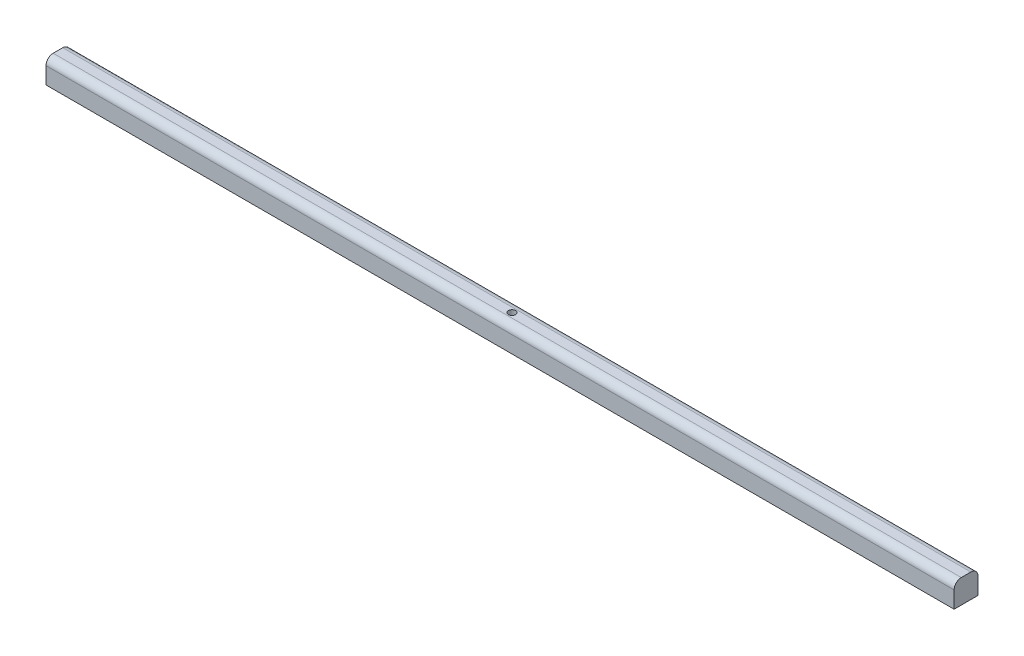
from build123d import *

# Parameters (mm, degrees)
SKETCH1_W           = 380
SKETCH1_H           = 10
BOSS_EXTRUDE1_DEPTH = 10
FILLET1_R           = 3
SKETCH2_R           = 1.5
CUT_EXTRUDE1_DEPTH  = 10


with BuildPart() as part:
    # Sketch1 → Boss-Extrude1 (new body)
    with BuildSketch(Plane(origin=(0, 0, 0), x_dir=(1, 0, 0), z_dir=(0, 1, 0))):
        Rectangle(SKETCH1_W, SKETCH1_H)
    extrude(amount=BOSS_EXTRUDE1_DEPTH)

    # Fillet1
    fillet1_edges = [part.edges().sort_by_distance(p)[0] for p in [
        (0, 10, 5),
        (0, 10, -5),
    ]]
    fillet(fillet1_edges, radius=FILLET1_R)

    # Sketch2 → Cut-Extrude1 (cut)
    with BuildSketch(Plane.XZ):
        Circle(SKETCH2_R)
    extrude(amount=-CUT_EXTRUDE1_DEPTH, mode=Mode.SUBTRACT)


solid = part.part
